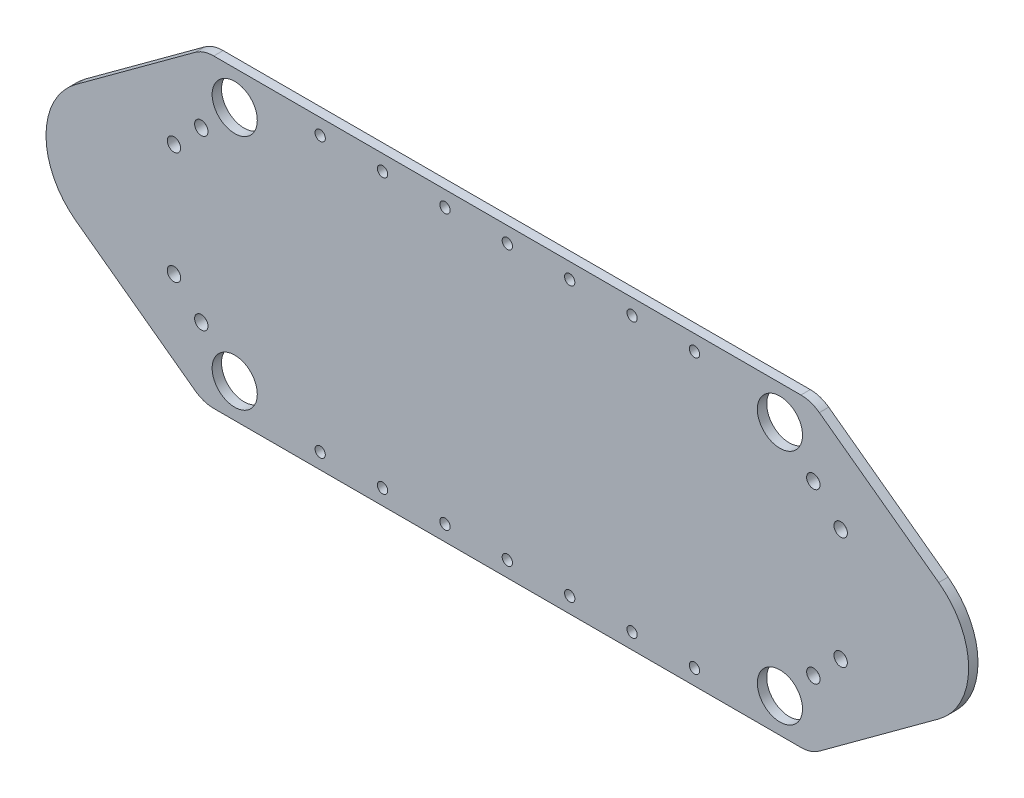
from build123d import *

# Parameters (mm, degrees)
SKETCH1_R           = 7.239
SKETCH1_R_2         = 2.15
SKETCH1_R_3         = 1.65
BOSS_EXTRUDE1_DEPTH = 3
FILLET1_R           = 10


with BuildPart() as part:
    # Sketch1 → Boss-Extrude1 (new body)
    with BuildSketch(Plane.XY):
        with BuildLine():
            Line((-87.4, 48.933577685), (87.4, 48.933577685))
            Line((87.4, 48.933577685), (97.4, 48.933577685))
            Line((97.4, 48.933577685), (138.294602876, 18.952308855))
            ThreePointArc((138.294602876, 18.952308855), (147.9, 0), (138.294602876, -18.952308855))
            Line((138.294602876, -18.952308855), (97.4, -48.933577685))
            Line((97.4, -48.933577685), (87.4, -48.933577685))
            Line((87.4, -48.933577685), (-87.4, -48.933577685))
            Line((-87.4, -48.933577685), (-97.4, -48.933577685))
            Line((-97.4, -48.933577685), (-138.294602876, -18.952308855))
            ThreePointArc((-138.294602876, -18.952308855), (-147.9, 0), (-138.294602876, 18.952308855))
            Line((-138.294602876, 18.952308855), (-97.4, 48.933577685))
            Line((-97.4, 48.933577685), (-87.4, 48.933577685))
        make_face()
        with Locations((-87.4, -38)):
            Circle(SKETCH1_R, mode=Mode.SUBTRACT)
        with Locations((-87.4, 38)):
            Circle(SKETCH1_R, mode=Mode.SUBTRACT)
        with Locations((87.4, -38)):
            Circle(SKETCH1_R, mode=Mode.SUBTRACT)
        with Locations((87.4, 38)):
            Circle(SKETCH1_R, mode=Mode.SUBTRACT)
        with Locations((98.110526316, -27)):
            Circle(SKETCH1_R_2, mode=Mode.SUBTRACT)
        with Locations((106.873684211, -18)):
            Circle(SKETCH1_R_2, mode=Mode.SUBTRACT)
        with Locations((106.873684211, 18)):
            Circle(SKETCH1_R_2, mode=Mode.SUBTRACT)
        with Locations((98.110526316, 27)):
            Circle(SKETCH1_R_2, mode=Mode.SUBTRACT)
        with Locations((-98.110526316, -27)):
            Circle(SKETCH1_R_2, mode=Mode.SUBTRACT)
        with Locations((-106.873684211, -18)):
            Circle(SKETCH1_R_2, mode=Mode.SUBTRACT)
        with Locations((-106.873684211, 18)):
            Circle(SKETCH1_R_2, mode=Mode.SUBTRACT)
        with Locations((-98.110526316, 27)):
            Circle(SKETCH1_R_2, mode=Mode.SUBTRACT)
        with Locations((-60, -43.933577685)):
            Circle(SKETCH1_R_3, mode=Mode.SUBTRACT)
        with Locations((0, 43.933577685)):
            Circle(SKETCH1_R_3, mode=Mode.SUBTRACT)
        with Locations((20, 43.933577685)):
            Circle(SKETCH1_R_3, mode=Mode.SUBTRACT)
        with Locations((40, 43.933577685)):
            Circle(SKETCH1_R_3, mode=Mode.SUBTRACT)
        with Locations((60, 43.933577685)):
            Circle(SKETCH1_R_3, mode=Mode.SUBTRACT)
        with Locations((-20, 43.933577685)):
            Circle(SKETCH1_R_3, mode=Mode.SUBTRACT)
        with Locations((-40, 43.933577685)):
            Circle(SKETCH1_R_3, mode=Mode.SUBTRACT)
        with Locations((-60, 43.933577685)):
            Circle(SKETCH1_R_3, mode=Mode.SUBTRACT)
        with Locations((-40, -43.933577685)):
            Circle(SKETCH1_R_3, mode=Mode.SUBTRACT)
        with Locations((-20, -43.933577685)):
            Circle(SKETCH1_R_3, mode=Mode.SUBTRACT)
        with Locations((0, -43.933577685)):
            Circle(SKETCH1_R_3, mode=Mode.SUBTRACT)
        with Locations((20, -43.933577685)):
            Circle(SKETCH1_R_3, mode=Mode.SUBTRACT)
        with Locations((40, -43.933577685)):
            Circle(SKETCH1_R_3, mode=Mode.SUBTRACT)
        with Locations((60, -43.933577685)):
            Circle(SKETCH1_R_3, mode=Mode.SUBTRACT)
    extrude(amount=BOSS_EXTRUDE1_DEPTH)

    # Fillet1
    fillet1_edges = [part.edges().sort_by_distance(p)[0] for p in [
        (-97.4, 48.933577685, 1.5),
        (97.4, 48.933577685, 1.5),
        (97.4, -48.933577685, 1.5),
        (-97.4, -48.933577685, 1.5),
    ]]
    fillet(fillet1_edges, radius=FILLET1_R)


solid = part.part
